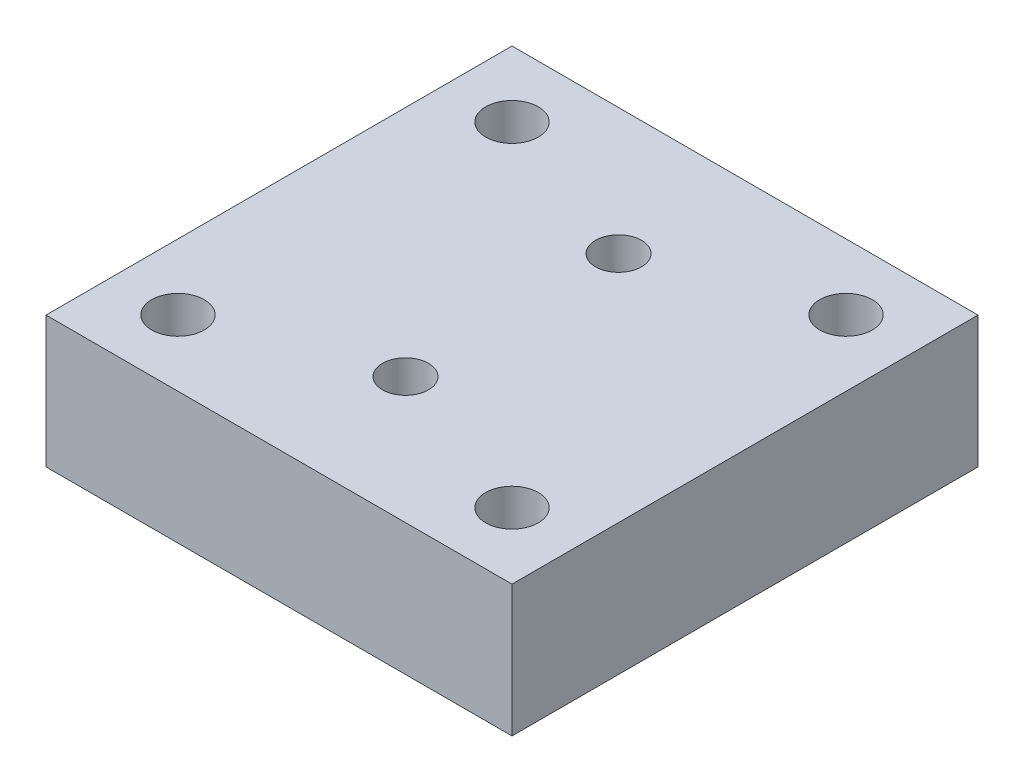
from build123d import *

# Parameters (mm, degrees)
SKETCH1_W            = 90
SKETCH1_H            = 90
BOSS_EXTRUDE1_DEPTH  = 25.4
SKETCH2_R            = 5.08
CUT_EXTRUDE1_DEPTH   = 50.8
LPATTERN1_COUNT      = 2
LPATTERN1_PITCH      = 64.516
LPATTERN1_COUNT_DIR2 = 2
LPATTERN1_PITCH_DIR2 = 64.516
SKETCH4_R            = 4.445
CUT_EXTRUDE3_DEPTH   = 26.4
SKETCH5_R            = 8.89
CUT_EXTRUDE4_DEPTH   = 7.62


with BuildPart() as part:
    # Sketch1 → Boss-Extrude1 (new body)
    with BuildSketch(Plane(origin=(0, 0, 0), x_dir=(1, 0, 0), z_dir=(0, 1, 0))):
        Rectangle(SKETCH1_W, SKETCH1_H)
    extrude(amount=BOSS_EXTRUDE1_DEPTH)

    # Sketch2 → Cut-Extrude1 (cut)
    with BuildSketch(Plane(origin=(0, 25.4, 0), x_dir=(-1, 0, 0), z_dir=(0, 1, 0))):
        with Locations((32.3, -32.3)):
            Circle(SKETCH2_R)
    cut_extrude1 = extrude(amount=-CUT_EXTRUDE1_DEPTH, mode=Mode.SUBTRACT)

    # LPattern1: Cut-Extrude1 2 × 2
    with Locations(*[(i * LPATTERN1_PITCH, 0, j * LPATTERN1_PITCH_DIR2) for i in range(LPATTERN1_COUNT) for j in range(LPATTERN1_COUNT_DIR2) if (i, j) != (0, 0)]):
        add(cut_extrude1, mode=Mode.SUBTRACT)

    # Sketch4 → Cut-Extrude3 (cut, through all)
    with BuildSketch(Plane(origin=(0, 25.4, 0), x_dir=(1, 0, 0), z_dir=(0, 1, 0))):
        with Locations((0, 20.574)):
            Circle(SKETCH4_R)
        with Locations((0, -20.574)):
            Circle(SKETCH4_R)
    extrude(amount=-CUT_EXTRUDE3_DEPTH, mode=Mode.SUBTRACT)

    # Sketch5 → Cut-Extrude4 (cut)
    with BuildSketch(Plane.XZ):
        with Locations((0, -20.574)):
            Circle(SKETCH5_R)
        with Locations((0, 20.574)):
            Circle(SKETCH5_R)
    extrude(amount=-CUT_EXTRUDE4_DEPTH, mode=Mode.SUBTRACT)


solid = part.part
